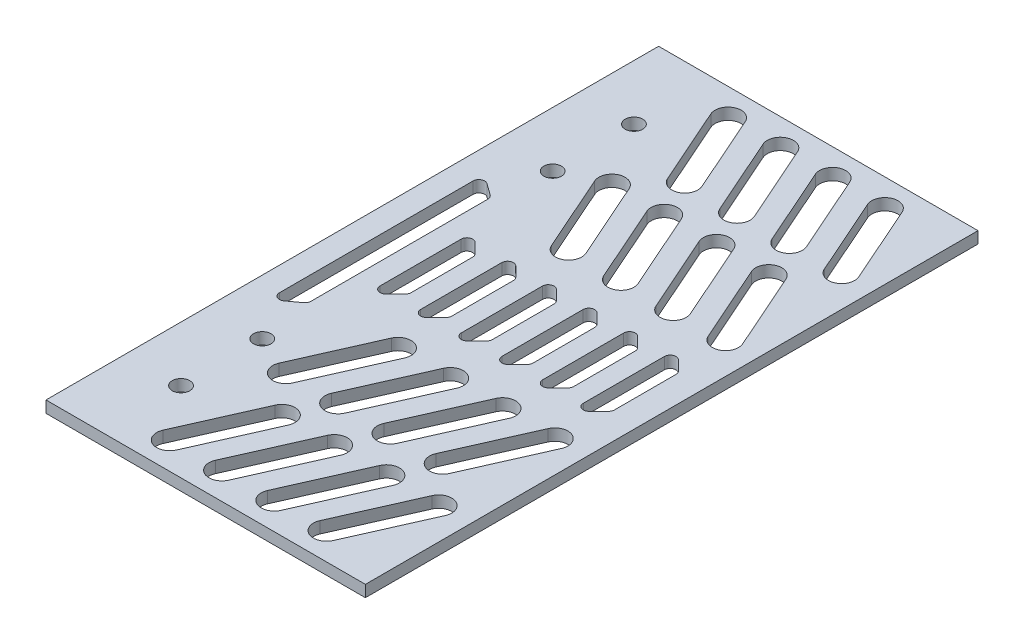
from build123d import *

# Parameters (mm, degrees)
SKETCH_1_W          = 55
SKETCH_1_H          = 2
EXTRUDE_1_DEPTH     = 105.5
SKETCH_2_R          = 1.51
CUT_EXTRUDE_1_DEPTH = 3


with BuildPart() as part:
    # 草图1 → 凸台-拉伸1 (new body)
    with BuildSketch(Plane.XY):
        with Locations((-27.5, 29)):
            Rectangle(SKETCH_1_W, SKETCH_1_H)
    extrude(amount=EXTRUDE_1_DEPTH)

    # 草图2 → 切除-拉伸1 (cut, through all)
    with BuildSketch(Plane(origin=(0, 30, 0), x_dir=(1, 0, 0), z_dir=(0, 1, 0))):
        with Locations((-45.5, -13.75)):
            Circle(SKETCH_2_R)
        with Locations((-45.5, -27.75)):
            Circle(SKETCH_2_R)
        with Locations((-45.5, -77.75)):
            Circle(SKETCH_2_R)
        with Locations((-45.5, -91.75)):
            Circle(SKETCH_2_R)
        with BuildLine():
            Line((-9.303061124, -3.764614363), (-3.380746275, -17.144659021))
            ThreePointArc((-3.380746275, -17.144659021), (-4.527817147, -20.113548336), (-7.496706463, -18.966477464))
            Line((-7.496706463, -18.966477464), (-13.419021311, -5.586432806))
            ThreePointArc((-13.419021311, -5.586432806), (-12.271950439, -2.617543491), (-9.303061124, -3.764614363))
        make_face()
        with BuildLine():
            Line((-18.303061124, -3.764614363), (-12.380746275, -17.144659021))
            ThreePointArc((-12.380746275, -17.144659021), (-13.527817147, -20.113548336), (-16.496706463, -18.966477464))
            Line((-16.496706463, -18.966477464), (-22.419021311, -5.586432806))
            ThreePointArc((-22.419021311, -5.586432806), (-21.271950439, -2.617543491), (-18.303061124, -3.764614363))
        make_face()
        with BuildLine():
            Line((-27.303061124, -3.764614363), (-21.380746275, -17.144659021))
            ThreePointArc((-21.380746275, -17.144659021), (-22.527817147, -20.113548336), (-25.496706463, -18.966477464))
            Line((-25.496706463, -18.966477464), (-31.419021311, -5.586432806))
            ThreePointArc((-31.419021311, -5.586432806), (-30.271950439, -2.617543491), (-27.303061124, -3.764614363))
        make_face()
        with BuildLine():
            Line((-36.303061124, -3.764614363), (-30.380746275, -17.144659021))
            ThreePointArc((-30.380746275, -17.144659021), (-31.527817147, -20.113548336), (-34.496706463, -18.966477464))
            Line((-34.496706463, -18.966477464), (-40.419021311, -5.586432806))
            ThreePointArc((-40.419021311, -5.586432806), (-39.271950439, -2.617543491), (-36.303061124, -3.764614363))
        make_face()
        with BuildLine():
            Line((-9.303061124, -23.764614363), (-3.380746275, -37.144659021))
            ThreePointArc((-3.380746275, -37.144659021), (-4.527817147, -40.113548336), (-7.496706463, -38.966477464))
            Line((-7.496706463, -38.966477464), (-13.419021311, -25.586432806))
            ThreePointArc((-13.419021311, -25.586432806), (-12.271950439, -22.617543491), (-9.303061124, -23.764614363))
        make_face()
        with BuildLine():
            Line((-18.303061124, -23.764614363), (-12.380746275, -37.144659021))
            ThreePointArc((-12.380746275, -37.144659021), (-13.527817147, -40.113548336), (-16.496706463, -38.966477464))
            Line((-16.496706463, -38.966477464), (-22.419021311, -25.586432806))
            ThreePointArc((-22.419021311, -25.586432806), (-21.271950439, -22.617543491), (-18.303061124, -23.764614363))
        make_face()
        with BuildLine():
            Line((-27.303061124, -23.764614363), (-21.380746275, -37.144659021))
            ThreePointArc((-21.380746275, -37.144659021), (-22.527817147, -40.113548336), (-25.496706463, -38.966477464))
            Line((-25.496706463, -38.966477464), (-31.419021311, -25.586432806))
            ThreePointArc((-31.419021311, -25.586432806), (-30.271950439, -22.617543491), (-27.303061124, -23.764614363))
        make_face()
        with BuildLine():
            Line((-36.303061124, -23.764614363), (-30.380746275, -37.144659021))
            ThreePointArc((-30.380746275, -37.144659021), (-31.527817147, -40.113548336), (-34.496706463, -38.966477464))
            Line((-34.496706463, -38.966477464), (-40.419021311, -25.586432806))
            ThreePointArc((-40.419021311, -25.586432806), (-39.271950439, -22.617543491), (-36.303061124, -23.764614363))
        make_face()
        with BuildLine():
            Line((-9.303061124, -81.735385637), (-3.380746275, -68.355340979))
            ThreePointArc((-3.380746275, -68.355340979), (-4.527817147, -65.386451664), (-7.496706463, -66.533522536))
            Line((-7.496706463, -66.533522536), (-13.419021311, -79.913567194))
            ThreePointArc((-13.419021311, -79.913567194), (-12.271950439, -82.882456509), (-9.303061124, -81.735385637))
        make_face()
        with BuildLine():
            Line((-18.303061124, -81.735385637), (-12.380746275, -68.355340979))
            ThreePointArc((-12.380746275, -68.355340979), (-13.527817147, -65.386451664), (-16.496706463, -66.533522536))
            Line((-16.496706463, -66.533522536), (-22.419021311, -79.913567194))
            ThreePointArc((-22.419021311, -79.913567194), (-21.271950439, -82.882456509), (-18.303061124, -81.735385637))
        make_face()
        with BuildLine():
            Line((-27.303061124, -81.735385637), (-21.380746275, -68.355340979))
            ThreePointArc((-21.380746275, -68.355340979), (-22.527817147, -65.386451664), (-25.496706463, -66.533522536))
            Line((-25.496706463, -66.533522536), (-31.419021311, -79.913567194))
            ThreePointArc((-31.419021311, -79.913567194), (-30.271950439, -82.882456509), (-27.303061124, -81.735385637))
        make_face()
        with BuildLine():
            Line((-36.303061124, -81.735385637), (-30.380746275, -68.355340979))
            ThreePointArc((-30.380746275, -68.355340979), (-31.527817147, -65.386451664), (-34.496706463, -66.533522536))
            Line((-34.496706463, -66.533522536), (-40.419021311, -79.913567194))
            ThreePointArc((-40.419021311, -79.913567194), (-39.271950439, -82.882456509), (-36.303061124, -81.735385637))
        make_face()
        with BuildLine():
            Line((-36.303061124, -101.735385637), (-30.380746275, -88.355340979))
            ThreePointArc((-30.380746275, -88.355340979), (-31.527817147, -85.386451664), (-34.496706463, -86.533522536))
            Line((-34.496706463, -86.533522536), (-40.419021311, -99.913567194))
            ThreePointArc((-40.419021311, -99.913567194), (-39.271950439, -102.882456509), (-36.303061124, -101.735385637))
        make_face()
        with BuildLine():
            Line((-27.303061124, -101.735385637), (-21.380746275, -88.355340979))
            ThreePointArc((-21.380746275, -88.355340979), (-22.527817147, -85.386451664), (-25.496706463, -86.533522536))
            Line((-25.496706463, -86.533522536), (-31.419021311, -99.913567194))
            ThreePointArc((-31.419021311, -99.913567194), (-30.271950439, -102.882456509), (-27.303061124, -101.735385637))
        make_face()
        with BuildLine():
            Line((-18.303061124, -101.735385637), (-12.380746275, -88.355340979))
            ThreePointArc((-12.380746275, -88.355340979), (-13.527817147, -85.386451664), (-16.496706463, -86.533522536))
            Line((-16.496706463, -86.533522536), (-22.419021311, -99.913567194))
            ThreePointArc((-22.419021311, -99.913567194), (-21.271950439, -102.882456509), (-18.303061124, -101.735385637))
        make_face()
        with BuildLine():
            Line((-9.303061124, -101.735385637), (-3.380746275, -88.355340979))
            ThreePointArc((-3.380746275, -88.355340979), (-4.527817147, -85.386451664), (-7.496706463, -86.533522536))
            Line((-7.496706463, -86.533522536), (-13.419021311, -99.913567194))
            ThreePointArc((-13.419021311, -99.913567194), (-12.271950439, -102.882456509), (-9.303061124, -101.735385637))
        make_face()
        with BuildLine():
            Line((-50.888412256, -69.431805303), (-50.888412256, -36.068194697))
            ThreePointArc((-50.888412256, -36.068194697), (-50.34341465, -35.177704483), (-49.302466613, -35.257844339))
            Line((-49.302466613, -35.257844339), (-47.314192301, -36.695519611))
            ThreePointArc((-47.314192301, -36.695519611), (-47.00964773, -37.050867575), (-46.900137944, -37.505869969))
            Line((-46.900137944, -37.505869969), (-46.900137944, -67.994130031))
            ThreePointArc((-46.900137944, -67.994130031), (-47.00964773, -68.449132425), (-47.314192301, -68.804480389))
            Line((-47.314192301, -68.804480389), (-49.302466613, -70.242155661))
            ThreePointArc((-49.302466613, -70.242155661), (-50.34341465, -70.322295517), (-50.888412256, -69.431805303))
        make_face()
        with BuildLine():
            Line((-43.242423956, -59.728557962), (-43.242423956, -45.771442038))
            ThreePointArc((-43.242423956, -45.771442038), (-42.625107389, -44.847562505), (-41.535317175, -45.064335256))
            Line((-41.535317175, -45.064335256), (-39.857028524, -46.742623908))
            ThreePointArc((-39.857028524, -46.742623908), (-39.640255772, -47.067047257), (-39.564135305, -47.449730689))
            Line((-39.564135305, -47.449730689), (-39.564135305, -58.050269311))
            ThreePointArc((-39.564135305, -58.050269311), (-39.640255772, -58.432952743), (-39.857028524, -58.757376092))
            Line((-39.857028524, -58.757376092), (-41.535317175, -60.435664744))
            ThreePointArc((-41.535317175, -60.435664744), (-42.625107389, -60.652437495), (-43.242423956, -59.728557962))
        make_face()
        with BuildLine():
            Line((-34.535317175, -60.435664744), (-32.857028524, -58.757376092))
            ThreePointArc((-32.857028524, -58.757376092), (-32.640255772, -58.432952743), (-32.564135305, -58.050269311))
            Line((-32.564135305, -58.050269311), (-32.564135305, -47.449730689))
            ThreePointArc((-32.564135305, -47.449730689), (-32.640255772, -47.067047257), (-32.857028524, -46.742623908))
            Line((-32.857028524, -46.742623908), (-34.535317175, -45.064335256))
            ThreePointArc((-34.535317175, -45.064335256), (-35.625107389, -44.847562505), (-36.242423956, -45.771442038))
            Line((-36.242423956, -45.771442038), (-36.242423956, -59.728557962))
            ThreePointArc((-36.242423956, -59.728557962), (-35.625107389, -60.652437495), (-34.535317175, -60.435664744))
        make_face()
        with BuildLine():
            Line((-27.535317175, -60.435664744), (-25.857028524, -58.757376092))
            ThreePointArc((-25.857028524, -58.757376092), (-25.640255772, -58.432952743), (-25.564135305, -58.050269311))
            Line((-25.564135305, -58.050269311), (-25.564135305, -47.449730689))
            ThreePointArc((-25.564135305, -47.449730689), (-25.640255772, -47.067047257), (-25.857028524, -46.742623908))
            Line((-25.857028524, -46.742623908), (-27.535317175, -45.064335256))
            ThreePointArc((-27.535317175, -45.064335256), (-28.625107389, -44.847562505), (-29.242423956, -45.771442038))
            Line((-29.242423956, -45.771442038), (-29.242423956, -59.728557962))
            ThreePointArc((-29.242423956, -59.728557962), (-28.625107389, -60.652437495), (-27.535317175, -60.435664744))
        make_face()
        with BuildLine():
            Line((-20.535317175, -60.435664744), (-18.857028524, -58.757376092))
            ThreePointArc((-18.857028524, -58.757376092), (-18.640255772, -58.432952743), (-18.564135305, -58.050269311))
            Line((-18.564135305, -58.050269311), (-18.564135305, -47.449730689))
            ThreePointArc((-18.564135305, -47.449730689), (-18.640255772, -47.067047257), (-18.857028524, -46.742623908))
            Line((-18.857028524, -46.742623908), (-20.535317175, -45.064335256))
            ThreePointArc((-20.535317175, -45.064335256), (-21.625107389, -44.847562505), (-22.242423956, -45.771442038))
            Line((-22.242423956, -45.771442038), (-22.242423956, -59.728557962))
            ThreePointArc((-22.242423956, -59.728557962), (-21.625107389, -60.652437495), (-20.535317175, -60.435664744))
        make_face()
        with BuildLine():
            Line((-13.535317175, -60.435664744), (-11.857028524, -58.757376092))
            ThreePointArc((-11.857028524, -58.757376092), (-11.640255772, -58.432952743), (-11.564135305, -58.050269311))
            Line((-11.564135305, -58.050269311), (-11.564135305, -47.449730689))
            ThreePointArc((-11.564135305, -47.449730689), (-11.640255772, -47.067047257), (-11.857028524, -46.742623908))
            Line((-11.857028524, -46.742623908), (-13.535317175, -45.064335256))
            ThreePointArc((-13.535317175, -45.064335256), (-14.625107389, -44.847562505), (-15.242423956, -45.771442038))
            Line((-15.242423956, -45.771442038), (-15.242423956, -59.728557962))
            ThreePointArc((-15.242423956, -59.728557962), (-14.625107389, -60.652437495), (-13.535317175, -60.435664744))
        make_face()
        with BuildLine():
            Line((-6.535317175, -60.435664744), (-4.857028524, -58.757376092))
            ThreePointArc((-4.857028524, -58.757376092), (-4.640255772, -58.432952743), (-4.564135305, -58.050269311))
            Line((-4.564135305, -58.050269311), (-4.564135305, -47.449730689))
            ThreePointArc((-4.564135305, -47.449730689), (-4.640255772, -47.067047257), (-4.857028524, -46.742623908))
            Line((-4.857028524, -46.742623908), (-6.535317175, -45.064335256))
            ThreePointArc((-6.535317175, -45.064335256), (-7.625107389, -44.847562505), (-8.242423956, -45.771442038))
            Line((-8.242423956, -45.771442038), (-8.242423956, -59.728557962))
            ThreePointArc((-8.242423956, -59.728557962), (-7.625107389, -60.652437495), (-6.535317175, -60.435664744))
        make_face()
    extrude(amount=-CUT_EXTRUDE_1_DEPTH, mode=Mode.SUBTRACT)


solid = part.part
